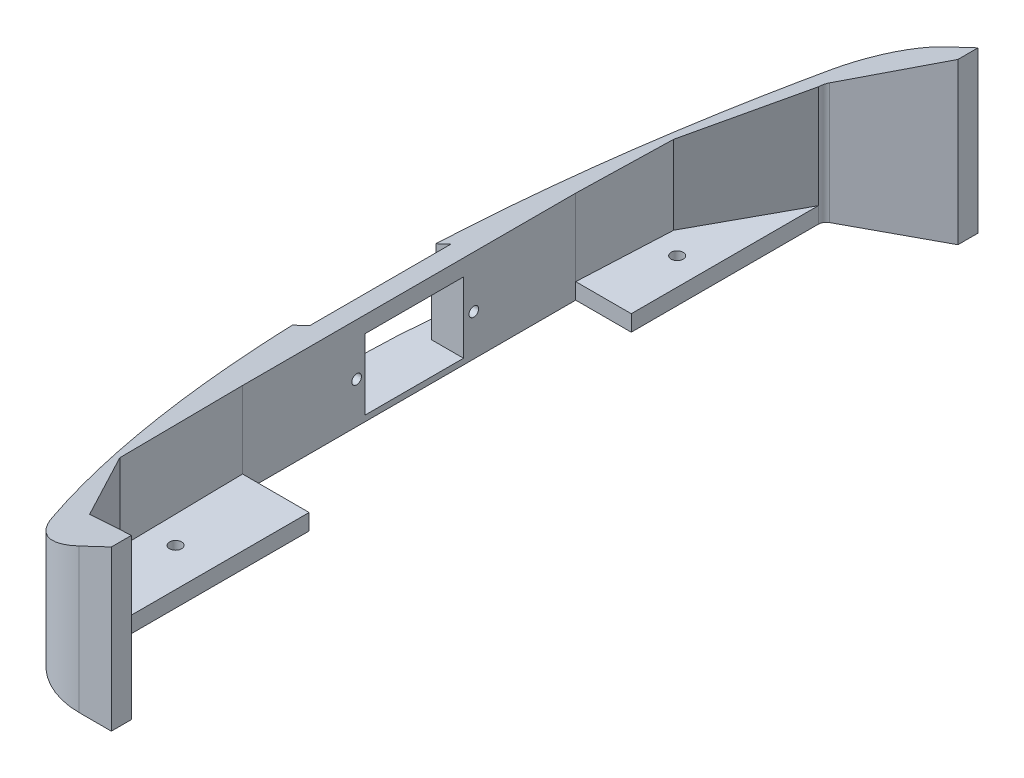
from build123d import *

# Parameters (mm, degrees)
FRONT_SKETCH_R      = 1.905
BOSS_EXTRUDE1_DEPTH = 50.8
CUT_EXTRUDE1_DEPTH  = 45.72
CUT_EXTRUDE2_DEPTH  = 274.638700861
CUT_EXTRUDE3_DEPTH  = 18.03621965
SKETCH6_W           = 6.524310643
SKETCH6_H           = 22.300846009
SKETCH6_R           = 1.524
SKETCH6_W_2         = 6.962786951
BOSS_EXTRUDE2_DEPTH = 10.16


with BuildPart() as part:
    # front_sketch → Boss-Extrude1 (new body)
    with BuildSketch(Plane(origin=(0, 0, 0), x_dir=(1, 0, 0), z_dir=(0, 1, 0))):
        with BuildLine():
            Line((-94.961375831, 124.478458264), (-121.345326632, 110.234521439))
            ThreePointArc((-121.345326632, 110.234521439), (-122.32001306, 109.300728329), (-122.678671172, 107.99944144))
            Line((-122.678671172, 107.99944144), (-122.678671172, 48.810796684))
            Line((-122.678671172, 48.810796684), (-140.250849959, 48.810796684))
            Line((-140.250849959, 48.810796684), (-140.250849959, -56.645199257))
            Line((-140.250849959, -56.645199257), (-119.167015715, -56.645199257))
            Line((-119.167015715, -56.645199257), (-119.167015715, -126.112255785))
            Line((-119.167015715, -126.112255785), (-95.601645083, -136.460242597))
            Line((-95.601645083, -136.460242597), (-95.601645083, -142.810242597))
            Line((-95.601645083, -142.810242597), (-105.798207048, -142.810242597))
            ThreePointArc((-105.798207048, -142.810242597), (-119.167015715, -139.007347839), (-128.532661201, -128.737404395))
            ThreePointArc((-128.532661201, -128.737404395), (-157.286213724, -5.861503432), (-127.918775374, 116.869125935))
            ThreePointArc((-127.918775374, 116.869125935), (-118.556014486, 127.058910858), (-105.241228699, 130.828458264))
            Line((-105.241228699, 130.828458264), (-94.961375831, 130.828458264))
            Line((-94.961375831, 130.828458264), (-94.961375831, 124.478458264))
        make_face()
        with Locations((-131.296368682, 71.963600743)):
            Circle(FRONT_SKETCH_R, mode=Mode.SUBTRACT)
        with Locations((-131.296368682, -86.786399257)):
            Circle(FRONT_SKETCH_R, mode=Mode.SUBTRACT)
    extrude(amount=BOSS_EXTRUDE1_DEPTH)

    # Sketch1 → Cut-Extrude1 (cut)
    with BuildSketch(Plane(origin=(0, 50.8, 0), x_dir=(1, 0, 0), z_dir=(0, 1, 0))):
        Polygon((-122.678671172, 48.810796684), (-122.678671172, 107.99944144), (-138.833286115, 78.405119062), (-140.250849959, 48.810796684), align=None)
        Polygon((-119.167015715, -56.645199257), (-140.250849959, -56.645199257), (-139.542068037, -96.192486205), (-119.167015715, -126.112255785), align=None)
    extrude(amount=-CUT_EXTRUDE1_DEPTH, mode=Mode.SUBTRACT)

    # Sketch3 → Cut-Extrude2 (cut, through all)
    with BuildSketch(Plane.XY.offset(142.810242597)):
        Polygon((-94.961375831, 50.8), (-157.287069608, 21.270817167), (-157.287069608, 50.8), align=None)
    extrude(amount=-CUT_EXTRUDE2_DEPTH, mode=Mode.SUBTRACT)

    # Sketch4 → Cut-Extrude3 (cut, through all)
    with BuildSketch(Plane(origin=(-140.250849959, 0, 0), x_dir=(0, 0, -1), z_dir=(1, 0, 0))):
        Polygon((-24.404629664, 24.144542412), (20.256333242, 24.144542412), (20.256333242, 5.094542412), (20.256333242, 1.843696403), (-24.404629664, 1.843696403), (-24.404629664, 5.094542412), align=None)
    extrude(amount=-CUT_EXTRUDE3_DEPTH, mode=Mode.SUBTRACT)

    # Sketch6 → Boss-Extrude2 (add)
    with BuildSketch(Plane(origin=(-140.250849959, 0, 0), x_dir=(0, 0, -1), z_dir=(1, 0, 0))):
        with Locations((-21.142474343, 12.994119407)):
            Rectangle(SKETCH6_W, SKETCH6_H)
        with Locations((-20.530013168, 12.991512488)):
            Circle(SKETCH6_R, mode=Mode.SUBTRACT)
        with Locations((16.774939767, 12.994119407)):
            Rectangle(SKETCH6_W_2, SKETCH6_H)
        with Locations((16.553986832, 12.991512488)):
            Circle(SKETCH6_R, mode=Mode.SUBTRACT)
    extrude(amount=-BOSS_EXTRUDE2_DEPTH)


solid = part.part
